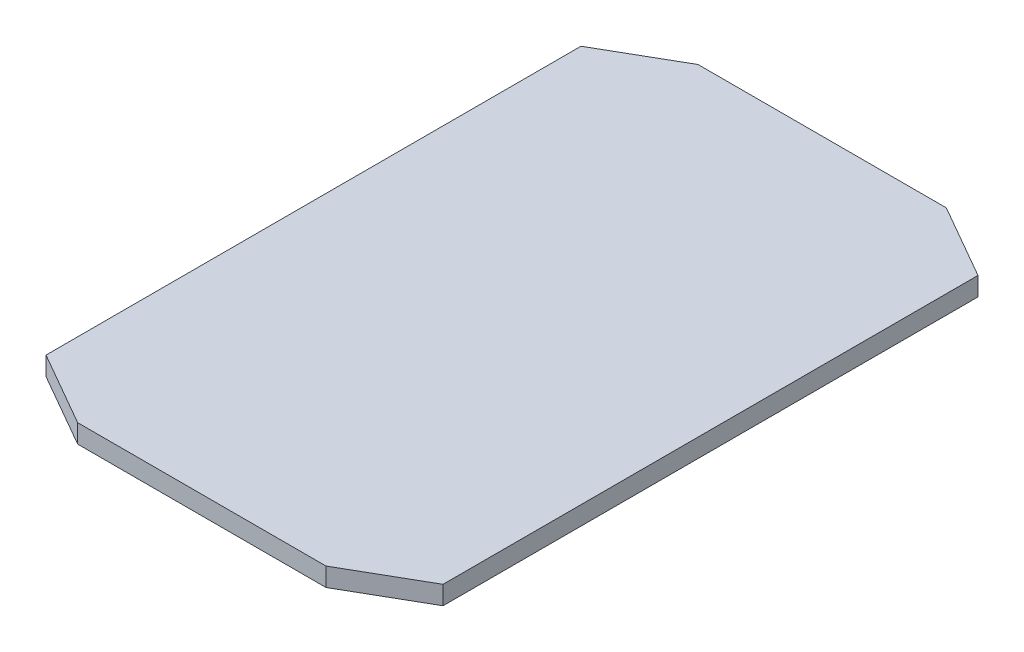
from build123d import *

# Parameters (mm, degrees)
BOSS_EXTRUDE1_DEPTH = 3


with BuildPart() as part:
    # Sketch1 → Boss-Extrude1 (new body)
    with BuildSketch(Plane(origin=(0, 0, 0), x_dir=(1, 0, 0), z_dir=(0, 1, 0))):
        Polygon((-32, -43.117707706), (-20.011895516, -50), (20.011895516, -50), (32, -43.117707706), (32, 43.117707706), (20.011895516, 50), (-20.011895516, 50), (-32, 43.117707706), align=None)
    extrude(amount=BOSS_EXTRUDE1_DEPTH)


solid = part.part
